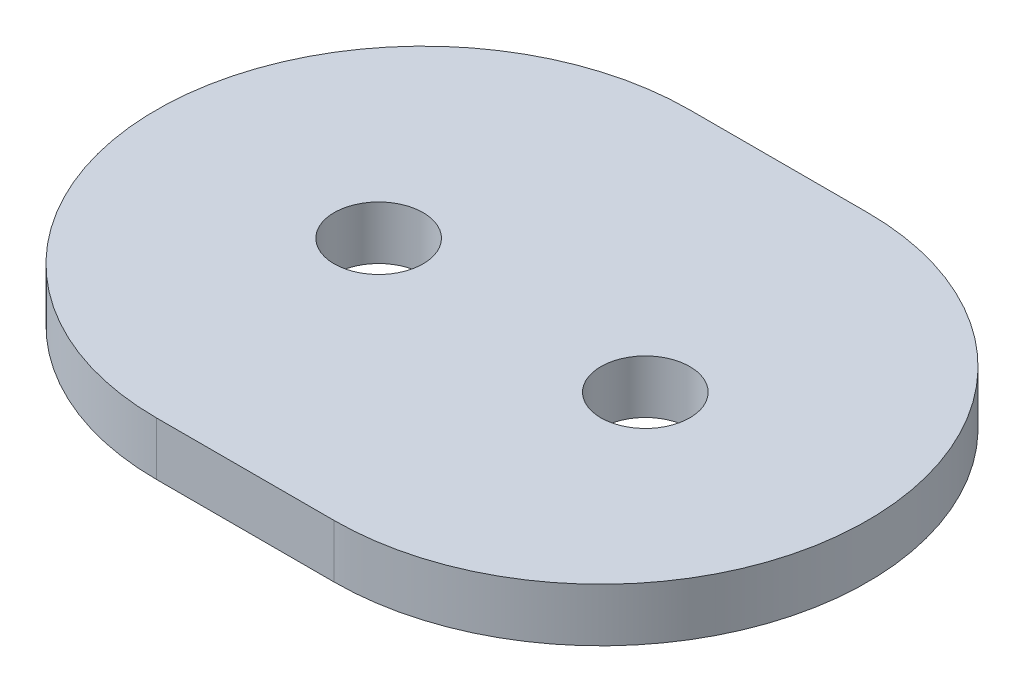
from build123d import *

# Parameters (mm, degrees)
ESQUISSE2_R        = 2.5
BOSS_EXTRU_1_DEPTH = 3


with BuildPart() as part:
    # Esquisse2 → Boss.-Extru.1 (new body)
    with BuildSketch(Plane(origin=(0, 0, 0), x_dir=(1, 0, 0), z_dir=(0, 1, 0))):
        with BuildLine():
            Line((-5, 15), (5, 15))
            ThreePointArc((5, 15), (20, 0), (5, -15))
            Line((5, -15), (-5, -15))
            ThreePointArc((-5, -15), (-20, 0), (-5, 15))
        make_face()
        with Locations((-7.5, 0)):
            Circle(ESQUISSE2_R, mode=Mode.SUBTRACT)
        with Locations((7.5, 0)):
            Circle(ESQUISSE2_R, mode=Mode.SUBTRACT)
    extrude(amount=BOSS_EXTRU_1_DEPTH)


solid = part.part
